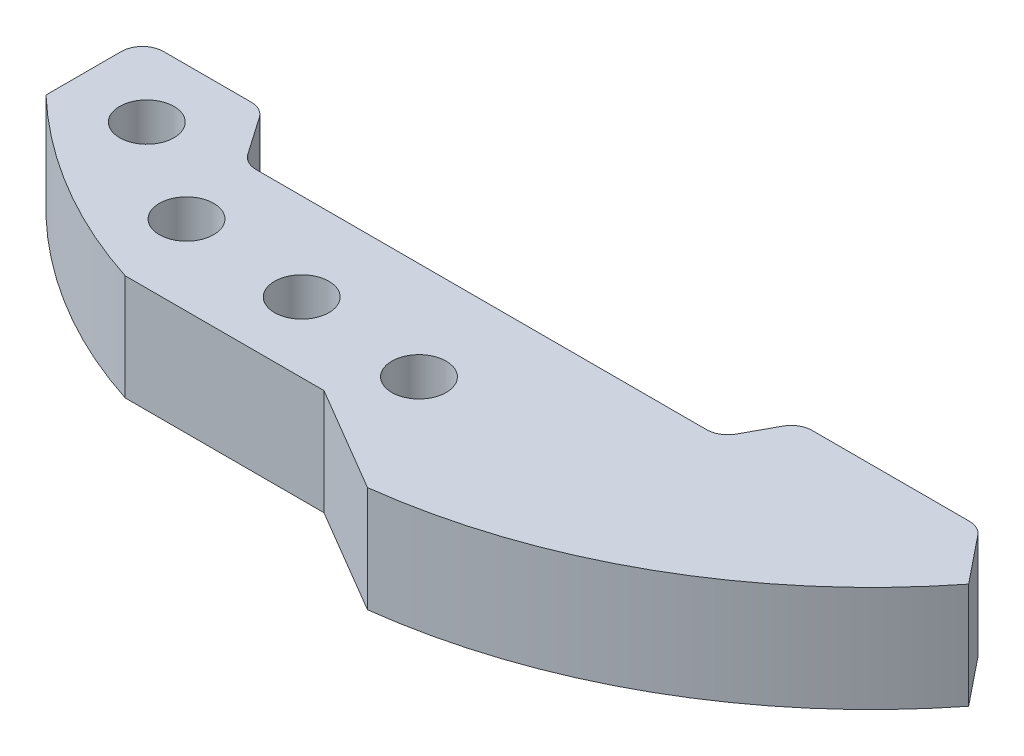
from build123d import *

# Parameters (mm, degrees)
SKETCH1_R           = 3.2639
BOSS_EXTRUDE1_DEPTH = 12.7


with BuildPart() as part:
    # Sketch1 → Boss-Extrude1 (new body)
    with BuildSketch(Plane(origin=(0, 0, 0), x_dir=(1, 0, 0), z_dir=(0, 1, 0))):
        with BuildLine():
            Line((-8.873253367, 0), (45.204292469, 0))
            ThreePointArc((45.204292469, 0), (46.502747155, 0.356971043), (47.436232768, 1.327546907))
            Line((47.436232768, 1.327546907), (49.391348597, 4.926615465))
            ThreePointArc((49.391348597, 4.926615465), (50.324834209, 5.897191329), (51.623288895, 6.254162372))
            Line((51.623288895, 6.254162372), (70.462087223, 6.254162372))
            ThreePointArc((70.462087223, 6.254162372), (71.559520533, 6.004847887), (72.441516032, 5.305847513))
            Line((72.441516032, 5.305847513), (76.972410672, -0.328799158))
            ThreePointArc((76.972410672, -0.328799158), (56.487992256, -17.897771795), (30.865519551, -26.369435729))
            Line((30.865519551, -26.369435729), (18.165519551, -18.896027316))
            Line((18.165519551, -18.896027316), (-5.688817186, -18.896027316))
            ThreePointArc((-5.688817186, -18.896027316), (-18.253794481, -13.20459823), (-29.23375861, -4.855262498))
            Line((-29.23375861, -4.855262498), (-29.23375861, 4.177286104))
            ThreePointArc((-29.23375861, 4.177286104), (-28.489809834, 5.973337328), (-26.69375861, 6.717286104))
            Line((-26.69375861, 6.717286104), (-16.191261416, 6.717286104))
            ThreePointArc((-16.191261416, 6.717286104), (-15.013419953, 6.427683732), (-14.10416564, 5.624915621))
            Line((-14.10416564, 5.624915621), (-10.960349143, 1.092370482))
            ThreePointArc((-10.960349143, 1.092370482), (-10.05109483, 0.289602371), (-8.873253367, 0))
        make_face()
        with Locations((-20.368787798, -1.624222444)):
            Circle(SKETCH1_R, mode=Mode.SUBTRACT)
        with Locations((-7.908365266, -9.317144856)):
            Circle(SKETCH1_R, mode=Mode.SUBTRACT)
        with Locations((7.107001098, -10.503835127)):
            Circle(SKETCH1_R, mode=Mode.SUBTRACT)
        with Locations((22.444824189, -11.767482364)):
            Circle(SKETCH1_R, mode=Mode.SUBTRACT)
    extrude(amount=BOSS_EXTRUDE1_DEPTH)


solid = part.part
